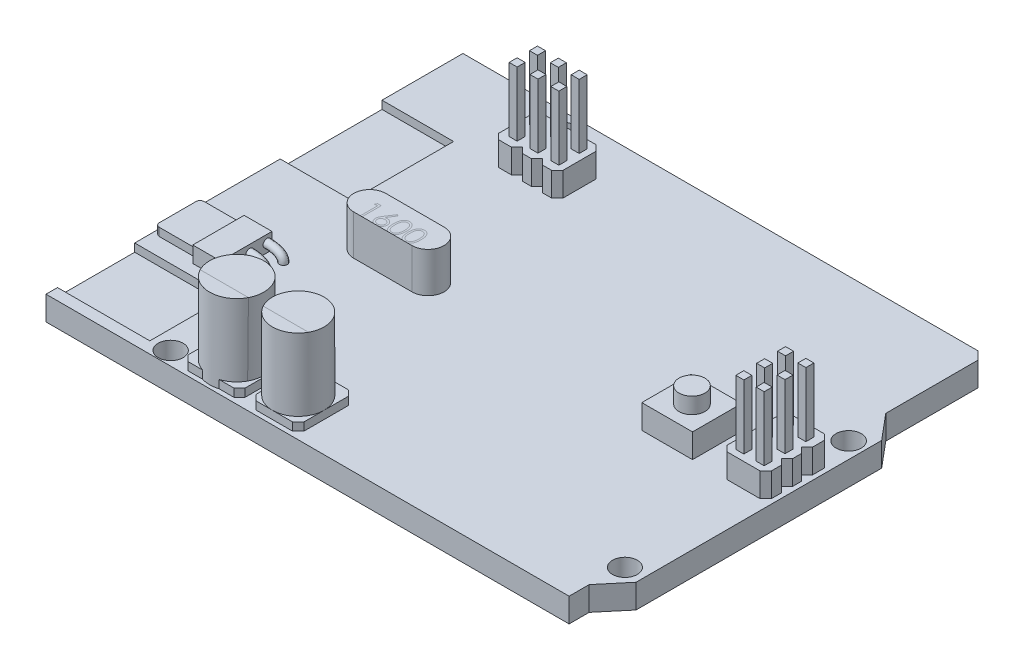
from build123d import *

# Parameters (mm, degrees)
SALIENTE_EXTRUIR7_DEPTH  = 3
CROQUIS8_W               = 6.322157445
CROQUIS8_H               = 6.13201561
CROQUIS8_R               = 1.616449318
SALIENTE_EXTRUIR8_DEPTH  = 3
CROQUIS8_3_R             = 1.616449318
SALIENTE_EXTRUIR9_DEPTH  = 5
CROQUIS8_4_R             = 1.57083537
CROQUIS8_4_R_2           = 1.545149395
CROQUIS8_4_R_3           = 1.559128108
CROQUIS8_4_R_4           = 1.743636228
CORTAR_EXTRUIR3_DEPTH    = 5
CROQUIS8_5_W             = 11.512655262
CROQUIS8_5_H             = 9.624843279
CROQUIS8_5_W_2           = 8.921351303
CROQUIS8_5_H_2           = 12.69238993
CORTAR_EXTRUIR4_DEPTH    = 1
CROQUIS9_W               = 1
CROQUIS9_H               = 1
SALIENTE_EXTRUIR10_DEPTH = 8
SALIENTE_EXTRUIR12_DEPTH = 1
CROQUIS10_5_R            = 3.382727059
CROQUIS10_5_R_2          = 3.223028124
SALIENTE_EXTRUIR14_DEPTH = 10
CROQUIS10_6_W            = 3.475867171
CROQUIS10_6_H            = 6.402913211
SALIENTE_EXTRUIR15_DEPTH = 2
CROQUIS11_R              = 0.5
CROQUIS11_3_R            = 0.5
CROQUIS11_4_R            = 0.5


with BuildPart() as part:
    # Croquis1 → Saliente-Extruir7 (new body)
    with BuildSketch(Plane(origin=(0, 0, 0), x_dir=(1, 0, 0), z_dir=(0, 1, 0))):
        Polygon((0, 0.974024098), (0, 52.950814499), (64.210980457, 52.950814499), (65.210980457, 51.950814499), (65.210980457, 40.450814499), (67.879433531, 37.270675962), (67.879433531, 6.654162635), (65.210980457, 3.474024098), (65.210980457, 0.974024098), align=None)
    extrude(amount=SALIENTE_EXTRUIR7_DEPTH)

    # Croquis8 → Saliente-Extruir8 (add)
    # profile 1 of 4: a face of its own
    with BuildSketch(Plane(origin=(0, 3, 0), x_dir=(1, 0, 0), z_dir=(0, 1, 0))):
        with BuildLine():
            Line((22.564615803, 28.034761906), (15.303580619, 28.034761906))
            ThreePointArc((15.303580619, 28.034761906), (13.303580619, 26.034761906), (15.303580619, 24.034761906))
            Line((15.303580619, 24.034761906), (22.564615803, 24.034761906))
            ThreePointArc((22.564615803, 24.034761906), (24.564615803, 26.034761906), (22.564615803, 28.034761906))
        make_face()
    # profile 2 of 4: a face of its own
    with BuildSketch(Plane(origin=(0, 3, 0), x_dir=(1, 0, 0), z_dir=(0, 1, 0))):
        Polygon((14.545757253, 48.397760644), (13.845757253, 47.697760644), (13.845757253, 43.562384515), (14.545757253, 42.862384515), (16.117489257, 42.862384515), (16.817489257, 43.562384515), (17.517489257, 42.862384515), (18.637750109, 42.862384515), (19.337750109, 43.562384515), (20.037750109, 42.862384515), (21.152323148, 42.862384515), (21.852323148, 43.562384515), (21.852323148, 47.697760644), (21.152323148, 48.397760644), (19.893368235, 48.397760644), (19.193368235, 47.697760644), (18.493368235, 48.397760644), (17.398017938, 48.397760644), (16.698017938, 47.697760644), (15.998017938, 48.397760644), align=None)
    # profile 3 of 4: a face of its own
    with BuildSketch(Plane(origin=(0, 3, 0), x_dir=(1, 0, 0), z_dir=(0, 1, 0))):
        Polygon((61.757878886, 30.711257805), (61.757878886, 29.1395258), (62.457878886, 28.4395258), (61.757878886, 27.7395258), (61.757878886, 26.619264949), (62.457878886, 25.919264949), (61.757878886, 25.219264949), (61.757878886, 24.10469191), (62.457878886, 23.40469191), (66.593255015, 23.40469191), (67.293255015, 24.10469191), (67.293255015, 25.363646823), (66.593255015, 26.063646823), (67.293255015, 26.763646823), (67.293255015, 27.85899712), (66.593255015, 28.55899712), (67.293255015, 29.25899712), (67.293255015, 30.711257805), (66.593255015, 31.411257805), (62.457878886, 31.411257805), align=None)
    # profile 4 of 4: a face of its own
    with BuildSketch(Plane(origin=(0, 3, 0), x_dir=(1, 0, 0), z_dir=(0, 1, 0))):
        with Locations((55.005785257, 26.470699715)):
            Rectangle(CROQUIS8_W, CROQUIS8_H)
        with Locations((55.135043625, 26.367344168)):
            Circle(CROQUIS8_R, mode=Mode.SUBTRACT)
    extrude(amount=SALIENTE_EXTRUIR8_DEPTH)

    # Croquis8_3 → Saliente-Extruir9 (add)
    with BuildSketch(Plane(origin=(0, 3, 0), x_dir=(1, 0, 0), z_dir=(0, 1, 0))):
        with BuildLine():
            Line((22.564615803, 28.034761906), (15.303580619, 28.034761906))
            ThreePointArc((15.303580619, 28.034761906), (13.303580619, 26.034761906), (15.303580619, 24.034761906))
            Line((15.303580619, 24.034761906), (22.564615803, 24.034761906))
            ThreePointArc((22.564615803, 24.034761906), (24.564615803, 26.034761906), (22.564615803, 28.034761906))
        make_face()
        with Locations((55.135043625, 26.367344168)):
            Circle(CROQUIS8_3_R)
    extrude(amount=SALIENTE_EXTRUIR9_DEPTH)

    # Croquis8_4 → Cortar-Extruir3 (cut)
    with BuildSketch(Plane(origin=(0, 3, 0), x_dir=(1, 0, 0), z_dir=(0, 1, 0))):
        with Locations((65.865737862, 35.167785549)):
            Circle(CROQUIS8_4_R)
        with Locations((65.577524156, 7.568491977)):
            Circle(CROQUIS8_4_R_2)
        with Locations((13.845757253, 2.668770395)):
            Circle(CROQUIS8_4_R_3)
        with Locations((14.698043544, 50.412417462)):
            Circle(CROQUIS8_4_R_4)
    extrude(amount=-CORTAR_EXTRUIR3_DEPTH, mode=Mode.SUBTRACT)

    # Croquis8_5 → Cortar-Extruir4 (cut)
    with BuildSketch(Plane(origin=(0, 3, 0), x_dir=(1, 0, 0), z_dir=(0, 1, 0))):
        with Locations((5.756327631, 7.218445228)):
            Rectangle(CROQUIS8_5_W, CROQUIS8_5_H)
        with Locations((4.460675651, 36.51618955)):
            Rectangle(CROQUIS8_5_W_2, CROQUIS8_5_H_2)
    extrude(amount=-CORTAR_EXTRUIR4_DEPTH, mode=Mode.SUBTRACT)

    # Croquis9 → Saliente-Extruir10 (add)
    with BuildSketch(Plane(origin=(0, 6, 0), x_dir=(1, 0, 0), z_dir=(0, 1, 0))):
        with Locations((15.345757253, 44.362384515)):
            Rectangle(CROQUIS9_W, CROQUIS9_H)
        with Locations((15.345757253, 46.897760644)):
            Rectangle(CROQUIS9_W, CROQUIS9_H)
        with Locations((17.945757253, 46.897760644)):
            Rectangle(CROQUIS9_W, CROQUIS9_H)
        with Locations((17.945757253, 44.362384515)):
            Rectangle(CROQUIS9_W, CROQUIS9_H)
        with Locations((20.545757253, 46.897760644)):
            Rectangle(CROQUIS9_W, CROQUIS9_H)
        with Locations((20.545757253, 44.362384515)):
            Rectangle(CROQUIS9_W, CROQUIS9_H)
        with Locations((63.257878886, 29.911257805)):
            Rectangle(CROQUIS9_W, CROQUIS9_H)
        with Locations((65.793255015, 29.911257805)):
            Rectangle(CROQUIS9_W, CROQUIS9_H)
        with Locations((63.257878886, 27.311257805)):
            Rectangle(CROQUIS9_W, CROQUIS9_H)
        with Locations((65.793255015, 27.311257805)):
            Rectangle(CROQUIS9_W, CROQUIS9_H)
        with Locations((63.257878886, 24.711257805)):
            Rectangle(CROQUIS9_W, CROQUIS9_H)
        with Locations((65.793255015, 24.711257805)):
            Rectangle(CROQUIS9_W, CROQUIS9_H)
    extrude(amount=SALIENTE_EXTRUIR10_DEPTH)

    # Croquis10 → Saliente-Extruir12 (add)
    with BuildSketch(Plane(origin=(0, 3, 0), x_dir=(1, 0, 0), z_dir=(0, 1, 0))):
        with BuildLine():
            Line((17.108152806, 8.494088208), (16.408152806, 7.794088208))
            Line((16.408152806, 7.794088208), (16.408152806, 2.250718797))
            Line((16.408152806, 2.250718797), (17.108152806, 1.550718797))
            Line((17.108152806, 1.550718797), (18.949544569, 1.550718797))
            ThreePointArc((18.949544569, 1.550718797), (19.976643428, 8.15647398), (21.003742287, 1.550718797))
            Line((21.003742287, 1.550718797), (22.845134051, 1.550718797))
            Line((22.845134051, 1.550718797), (23.545134051, 2.250718797))
            Line((23.545134051, 2.250718797), (23.545134051, 7.794088208))
            Line((23.545134051, 7.794088208), (22.845134051, 8.494088208))
            Line((22.845134051, 8.494088208), (17.108152806, 8.494088208))
        make_face()
        with BuildLine():
            Line((5.83538594, 19.836941928), (0.847174616, 19.836941928))
            ThreePointArc((0.847174616, 19.836941928), (0.493621225, 19.690495319), (0.347174616, 19.336941928))
            Line((0.347174616, 19.336941928), (0.347174616, 14.757260416))
            ThreePointArc((0.347174616, 14.757260416), (0.493621225, 14.403707025), (0.847174616, 14.257260416))
            Line((0.847174616, 14.257260416), (5.83538594, 14.257260416))
            Line((5.83538594, 14.257260416), (5.83538594, 19.836941928))
        make_face()
        with BuildLine():
            Line((30.168130124, 8.494088208), (25.611790034, 8.494088208))
            Line((25.611790034, 8.494088208), (24.911790034, 7.794088208))
            Line((24.911790034, 7.794088208), (24.911790034, 6.48164504))
            ThreePointArc((24.911790034, 6.48164504), (24.422073875, 4.773746921), (24.911790034, 3.065848802))
            Line((24.911790034, 3.065848802), (24.911790034, 2.250718797))
            Line((24.911790034, 2.250718797), (25.611790034, 1.550718797))
            Line((25.611790034, 1.550718797), (30.168130124, 1.550718797))
            Line((30.168130124, 1.550718797), (30.868130124, 2.250718797))
            Line((30.868130124, 2.250718797), (30.868130124, 7.794088208))
            Line((30.868130124, 7.794088208), (30.168130124, 8.494088208))
        make_face()
    extrude(amount=SALIENTE_EXTRUIR12_DEPTH)

    # Croquis10_5 → Saliente-Extruir14 (add)
    with BuildSketch(Plane(origin=(0, 3, 0), x_dir=(1, 0, 0), z_dir=(0, 1, 0))):
        with Locations((19.976643428, 4.773746921)):
            Circle(CROQUIS10_5_R)
        with Locations((27.645102, 4.773746921)):
            Circle(CROQUIS10_5_R_2)
    extrude(amount=SALIENTE_EXTRUIR14_DEPTH)

    # Croquis10_6 → Saliente-Extruir15 (add)
    with BuildSketch(Plane(origin=(0, 3, 0), x_dir=(1, 0, 0), z_dir=(0, 1, 0))):
        with Locations((7.573319526, 16.635485323)):
            Rectangle(CROQUIS10_6_W, CROQUIS10_6_H)
    extrude(amount=SALIENTE_EXTRUIR15_DEPTH)

    # Barrer1: sweep along a curve in space
    with BuildLine() as barrer1_path:
        add(Edge.make_bspline(
            [(9.311253111, 4.060960074, -14.574434934), (10.074973999, 4.060960074, -14.574434934), (11.341964499, 3.921132529, -14.574434933), (11.341964499, 3, -14.574434933)],
            knots=[0, 0, 0, 0, 1, 1, 1, 1], degree=3))
    # Croquis11 → Barrer1 (sweep)
    with BuildSketch(Plane(origin=(9.311253111, 0, 0), x_dir=(0, 0, -1), z_dir=(1, 0, 0))):
        with Locations((14.574434934, 4.060960074)):
            Circle(CROQUIS11_R)
    sweep(path=barrer1_path.line)

    # Barrer3: sweep along a curve in space
    with BuildLine() as barrer3_path:
        add(Edge.make_bspline(
            [(9.311253111, 4.060960074, -17.074434934), (10.074973999, 4.060960074, -17.074434934), (11.341964499, 3.921132529, -17.074434933), (11.341964499, 3, -17.074434933)],
            knots=[0, 0, 0, 0, 1, 1, 1, 1], degree=3))
    # Croquis11_3 → Barrer3 (sweep)
    with BuildSketch(Plane(origin=(9.311253111, 0, 0), x_dir=(0, 0, -1), z_dir=(1, 0, 0))):
        with Locations((17.059408509, 4.060960074)):
            Circle(CROQUIS11_3_R)
    sweep(path=barrer3_path.line)

    # Barrer4: sweep along a curve in space
    with BuildLine() as barrer4_path:
        add(Edge.make_bspline(
            [(9.311253111, 4.060960074, -19.274434934), (10.074973999, 4.060960074, -19.274434934), (11.341964499, 3.921132529, -19.274434933), (11.341964499, 3, -19.274434933)],
            knots=[0, 0, 0, 0, 1, 1, 1, 1], degree=3))
    # Croquis11_4 → Barrer4 (sweep)
    with BuildSketch(Plane(origin=(9.311253111, 0, 0), x_dir=(0, 0, -1), z_dir=(1, 0, 0))):
        with Locations((19.220728949, 4.060960074)):
            Circle(CROQUIS11_4_R)
    sweep(path=barrer4_path.line)


solid = part.part
